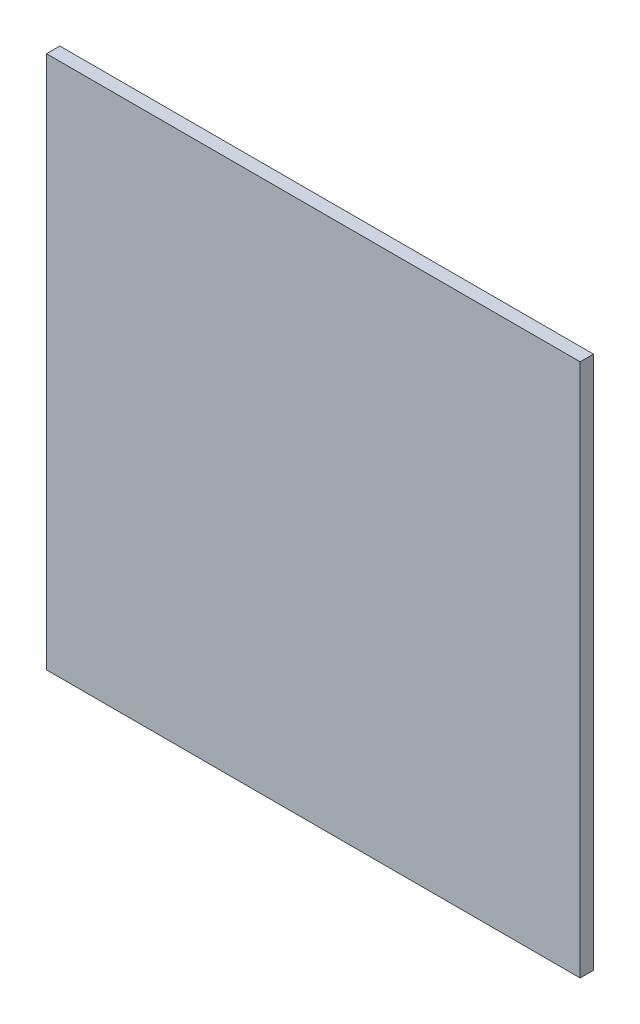
from build123d import *

# Parameters (mm, degrees)
SKETCH1_W           = 400
SKETCH1_H           = 400
BOSS_EXTRUDE1_DEPTH = 10


with BuildPart() as part:
    # Sketch1 → Boss-Extrude1 (new body)
    with BuildSketch(Plane.XY):
        with Locations((200, 200)):
            Rectangle(SKETCH1_W, SKETCH1_H)
    extrude(amount=BOSS_EXTRUDE1_DEPTH)


solid = part.part
